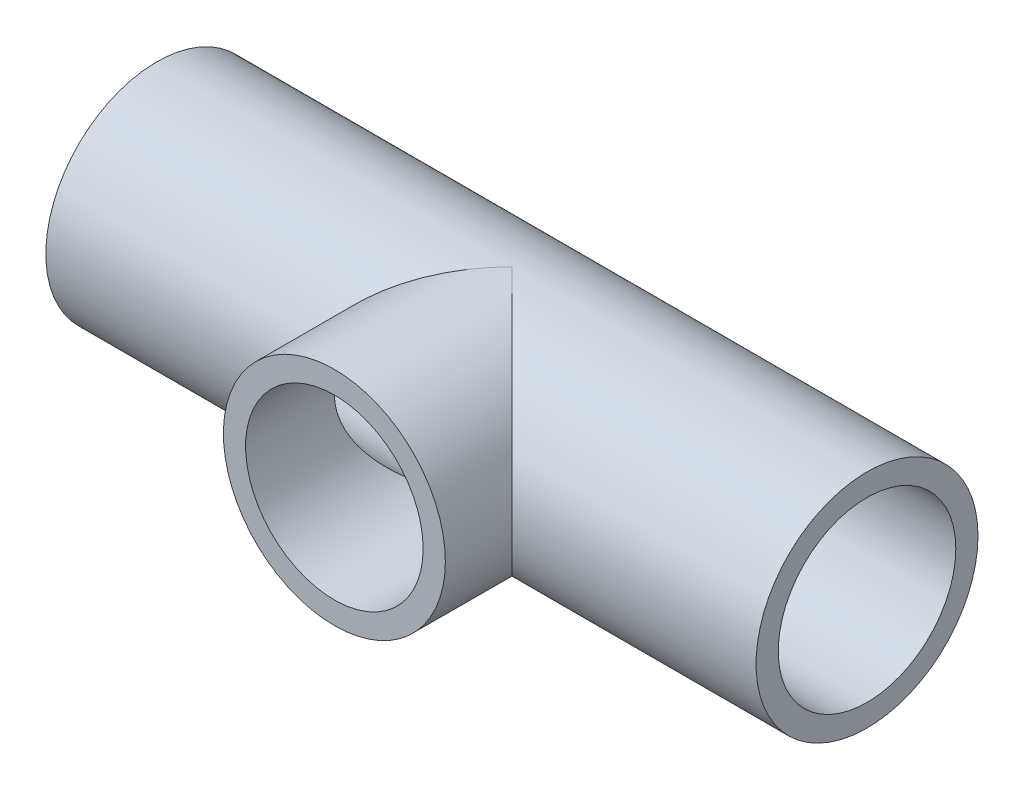
from build123d import *

# Parameters (mm, degrees)
SKETCH4_R           = 7.9375
BOSS_EXTRUDE2_DEPTH = 12.7
SKETCH7_R           = 6.35
CUT_EXTRUDE2_DEPTH  = 12.7
SKETCH8_R           = 7.9375
BOSS_EXTRUDE4_DEPTH = 25.4
SKETCH10_R          = 6.35
CUT_EXTRUDE4_DEPTH  = 12.7
SKETCH9_R           = 6.35
CUT_EXTRUDE5_DEPTH  = 51.8


with BuildPart() as part:
    # Sketch4 → Boss-Extrude2 (new body)
    with BuildSketch(Plane.XY):
        Circle(SKETCH4_R)
    extrude(amount=BOSS_EXTRUDE2_DEPTH)

    # Sketch7 → Cut-Extrude2 (cut)
    with BuildSketch(Plane.XY.offset(12.7)):
        Circle(SKETCH7_R)
    extrude(amount=-CUT_EXTRUDE2_DEPTH, mode=Mode.SUBTRACT)

    # Sketch8 → Boss-Extrude4 (add, symmetric)
    with BuildSketch(Plane(origin=(0, 0, 0), x_dir=(0, 0, -1), z_dir=(1, 0, 0))):
        Circle(SKETCH8_R)
    extrude(amount=BOSS_EXTRUDE4_DEPTH, both=True)

    # Sketch10 → Cut-Extrude4 (cut)
    with BuildSketch(Plane.XY.offset(12.7)):
        Circle(SKETCH10_R)
    extrude(amount=-CUT_EXTRUDE4_DEPTH, mode=Mode.SUBTRACT)

    # Sketch9 → Cut-Extrude5 (cut, through all)
    with BuildSketch(Plane(origin=(25.4, 0, 0), x_dir=(0, 0, -1), z_dir=(1, 0, 0))):
        Circle(SKETCH9_R)
    extrude(amount=-CUT_EXTRUDE5_DEPTH, mode=Mode.SUBTRACT)


solid = part.part
